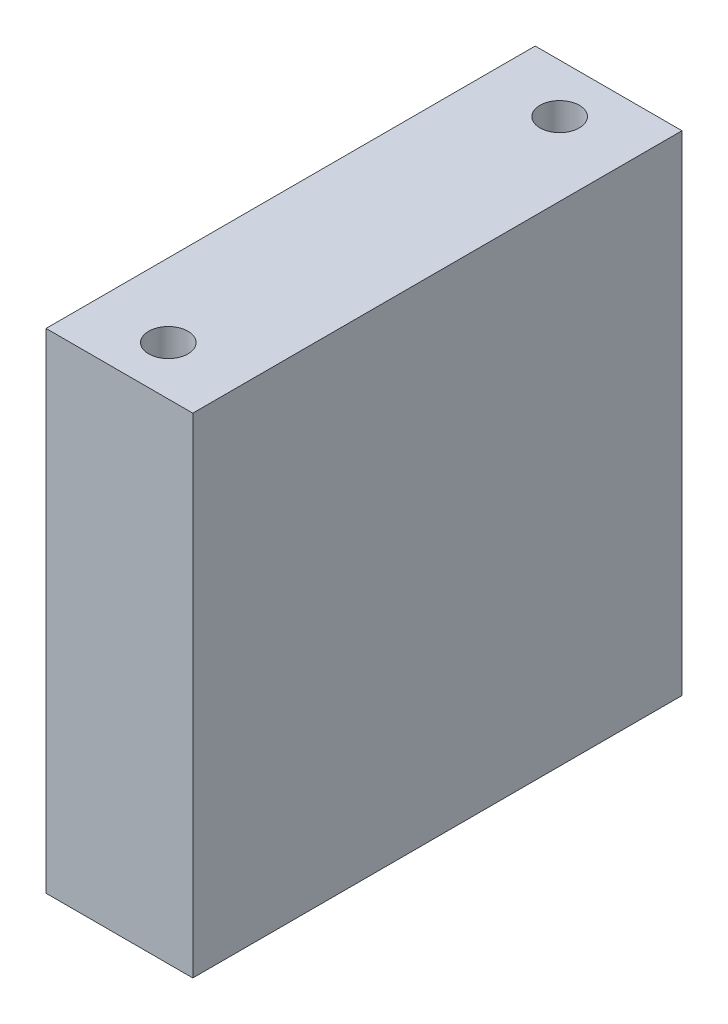
from build123d import *

# Parameters (mm, degrees)
SKETCH1_W                   = 19.05
SKETCH1_H                   = 63.5
BOSS_EXTRUDE1_DEPTH         = 63.5
F_1_4_20_TAPPED_HOLE1_D     = 5.1054
F_1_4_20_TAPPED_HOLE1_DEPTH = 16.51
F_1_4_20_TAPPED_HOLE1_TIP   = 1.533816902
F_1_4_20_TAPPED_HOLE2_D     = 5.1054
F_1_4_20_TAPPED_HOLE2_DEPTH = 16.51
F_1_4_20_TAPPED_HOLE2_TIP   = 1.533816902


with BuildPart() as part:
    # Sketch1 → Boss-Extrude1 (new body)
    with BuildSketch(Plane(origin=(0, 0, 0), x_dir=(1, 0, 0), z_dir=(0, 1, 0))):
        Rectangle(SKETCH1_W, SKETCH1_H)
    extrude(amount=BOSS_EXTRUDE1_DEPTH)

    # 1/4-20 Tapped Hole1
    with Locations(Plane(origin=(0, 0, 0), x_dir=(-1, 0, 0), z_dir=(0, -1, 0))):
        with Locations((0, -25.4), (0, 25.4)):
            Hole(F_1_4_20_TAPPED_HOLE1_D / 2, depth=F_1_4_20_TAPPED_HOLE1_DEPTH)
            with Locations((0, 0, -(F_1_4_20_TAPPED_HOLE1_DEPTH + F_1_4_20_TAPPED_HOLE1_TIP / 2))):  # 118° drill point
                Cone(0, F_1_4_20_TAPPED_HOLE1_D / 2, F_1_4_20_TAPPED_HOLE1_TIP, mode=Mode.SUBTRACT)

    # 1/4-20 Tapped Hole2
    with Locations(Plane(origin=(0, 63.5, 0), x_dir=(1, 0, 0), z_dir=(0, 1, 0))):
        with Locations((0, 25.4), (0, -25.4)):
            Hole(F_1_4_20_TAPPED_HOLE2_D / 2, depth=F_1_4_20_TAPPED_HOLE2_DEPTH)
            with Locations((0, 0, -(F_1_4_20_TAPPED_HOLE2_DEPTH + F_1_4_20_TAPPED_HOLE2_TIP / 2))):  # 118° drill point
                Cone(0, F_1_4_20_TAPPED_HOLE2_D / 2, F_1_4_20_TAPPED_HOLE2_TIP, mode=Mode.SUBTRACT)


solid = part.part
